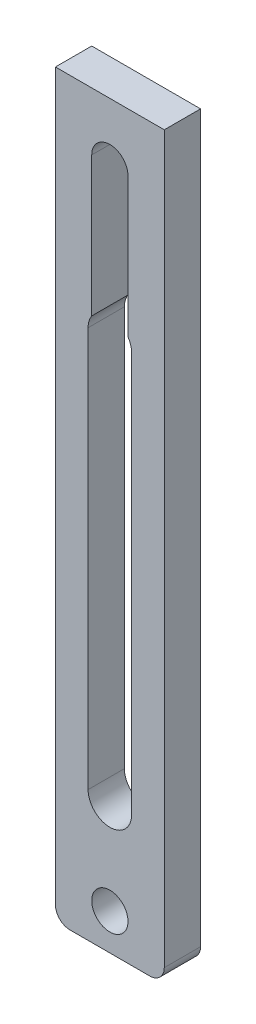
from build123d import *

# Parameters (mm, degrees)
SKETCH1_R               = 3.175
BOSS_EXTRUDE1_DEPTH     = 6.35
CUT_EXTRUDE1_DEPTH      = 1
CUT_EXTRUDE1_DEPTH_BACK = 7.35
CUT_EXTRUDE2_DEPTH      = 7.35


with BuildPart() as part:
    # Sketch1 → Boss-Extrude1 (new body)
    with BuildSketch(Plane.XY):
        with BuildLine():
            Line((-6.985, -64.77), (6.985, -64.77))
            ThreePointArc((6.985, -64.77), (8.781051224, -64.026051224), (9.525, -62.23))
            Line((9.525, -62.23), (9.525, 64.77))
            Line((9.525, 64.77), (-9.525, 64.77))
            Line((-9.525, 64.77), (-9.525, -62.23))
            ThreePointArc((-9.525, -62.23), (-8.781051224, -64.026051224), (-6.985, -64.77))
        make_face()
        with Locations((0, -58.42)):
            Circle(SKETCH1_R, mode=Mode.SUBTRACT)
    extrude(amount=BOSS_EXTRUDE1_DEPTH)

    # Sketch2 → Cut-Extrude1 (cut, two sides)
    with BuildSketch(Plane.XY.offset(6.35)) as cut_extrude1_sk:
        with BuildLine():
            Line((-3.175, -41.91), (-3.175, 54.61))
            ThreePointArc((-3.175, 54.61), (0, 57.785), (3.175, 54.61))
            Line((3.175, 54.61), (3.175, -41.91))
            ThreePointArc((3.175, -41.91), (0, -45.085), (-3.175, -41.91))
        make_face()
    extrude(amount=CUT_EXTRUDE1_DEPTH, mode=Mode.SUBTRACT)
    extrude(cut_extrude1_sk.sketch, amount=-CUT_EXTRUDE1_DEPTH_BACK, mode=Mode.SUBTRACT)

    # Sketch3 → Cut-Extrude2 (cut, through all)
    with BuildSketch(Plane.XY.offset(6.35)):
        with BuildLine():
            Line((3.81, 28.098134356), (3.81, -41.91))
            ThreePointArc((3.81, -41.91), (0, -45.72), (-3.81, -41.91))
            Line((-3.81, -41.91), (-3.81, 28.098134356))
            ThreePointArc((-3.81, 28.098134356), (0, 31.908134356), (3.81, 28.098134356))
        make_face()
    extrude(amount=-CUT_EXTRUDE2_DEPTH, mode=Mode.SUBTRACT)


solid = part.part
